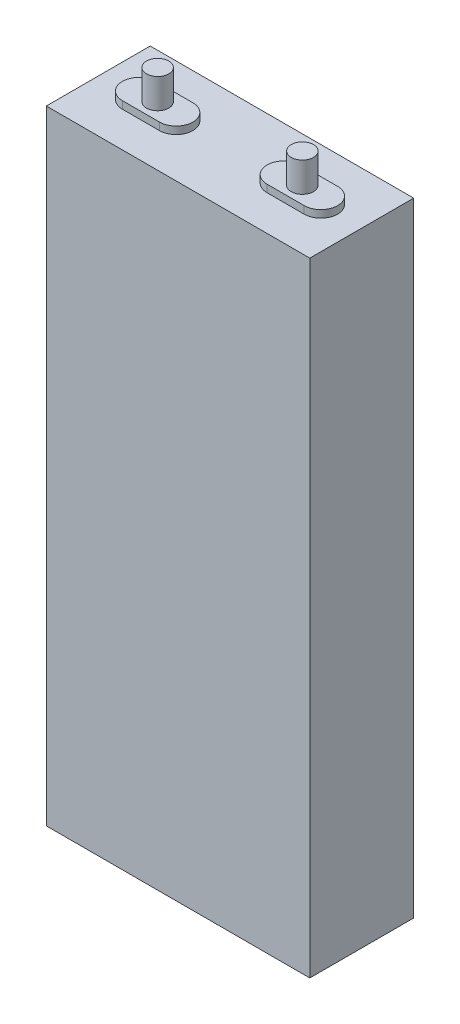
from build123d import *

# Parameters (mm, degrees)
ESQUISSE1_W        = 71
ESQUISSE1_H        = 28
BOSS_EXTRU_1_DEPTH = 168
BOSS_EXTRU_2_DEPTH = 2
ESQUISSE3_R        = 3
BOSS_EXTRU_3_DEPTH = 8


with BuildPart() as part:
    # Esquisse1 → Boss.-Extru.1 (new body)
    with BuildSketch(Plane(origin=(0, 0, 0), x_dir=(1, 0, 0), z_dir=(0, 1, 0))):
        Rectangle(ESQUISSE1_W, ESQUISSE1_H)
    extrude(amount=BOSS_EXTRU_1_DEPTH)

    # Esquisse2 → Boss.-Extru.2 (add)
    with BuildSketch(Plane(origin=(0, 168, 0), x_dir=(1, 0, 0), z_dir=(0, 1, 0))):
        with BuildLine():
            Line((-24.5, 4.5), (-14.5, 4.5))
            ThreePointArc((-14.5, 4.5), (-10, 0), (-14.5, -4.5))
            Line((-14.5, -4.5), (-24.5, -4.5))
            ThreePointArc((-24.5, -4.5), (-29, 0), (-24.5, 4.5))
        make_face()
        with BuildLine():
            Line((24.5, 4.5), (14.5, 4.5))
            ThreePointArc((14.5, 4.5), (10, 0), (14.5, -4.5))
            Line((14.5, -4.5), (24.5, -4.5))
            ThreePointArc((24.5, -4.5), (29, 0), (24.5, 4.5))
        make_face()
    extrude(amount=BOSS_EXTRU_2_DEPTH)

    # Esquisse3 → Boss.-Extru.3 (add)
    with BuildSketch(Plane(origin=(0, 170, 0), x_dir=(1, 0, 0), z_dir=(0, 1, 0))):
        with Locations((-19.5, 0)):
            Circle(ESQUISSE3_R)
        with Locations((19.5, 0)):
            Circle(ESQUISSE3_R)
    extrude(amount=BOSS_EXTRU_3_DEPTH)


solid = part.part
